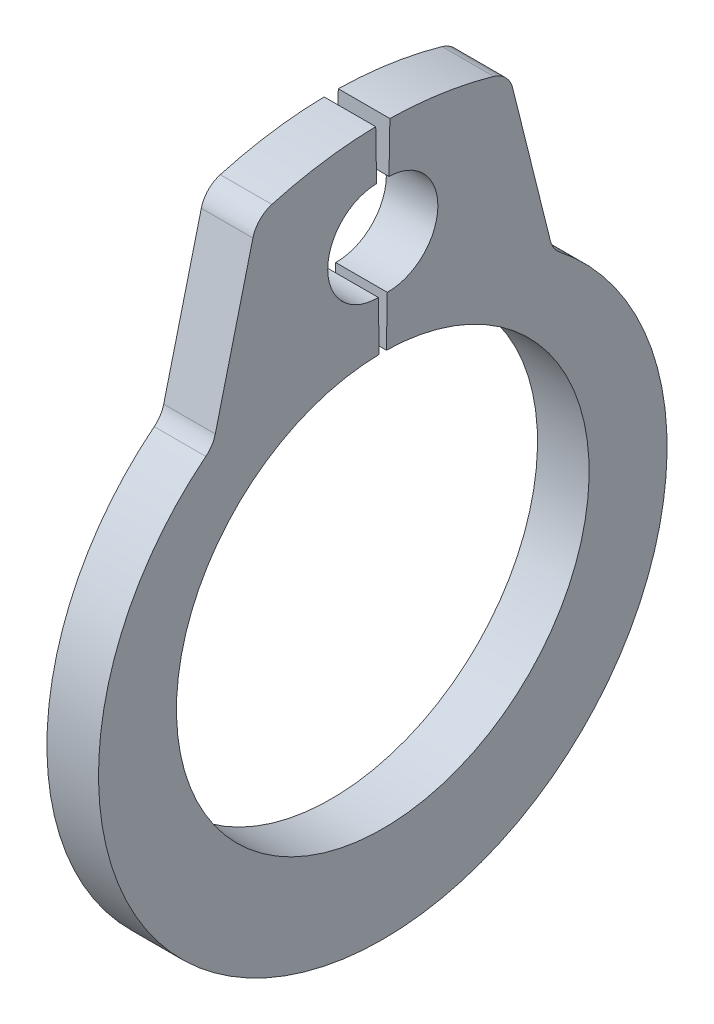
from build123d import *

# Parameters (mm, degrees)
EXTRUDE1_DEPTH = 0.35
FILLET1_R      = 0.37


with BuildPart() as part:
    # Sketch1 → Extrude1 (new body, symmetric)
    with BuildSketch(Plane(origin=(0, 0, 0), x_dir=(0, 0, -1), z_dir=(1, 0, 0))):
        with BuildLine():
            Line((0.048866738, 2.799573546), (0.060647112, 3.474470741))
            ThreePointArc((0.060647112, 3.474470741), (0.747324681, 4.137587561), (0.084207861, 4.824265129))
            Line((0.084207861, 4.824265129), (0.095988235, 5.499162323))
            ThreePointArc((0.095988235, 5.499162323), (0.91428004, 5.423476008), (1.712160583, 5.226710834))
            Line((1.712160583, 5.226710834), (2.304187375, 2.852221062))
            ThreePointArc((2.304187375, 2.852221062), (0, -4.1), (-2.304187375, 2.852221062))
            Line((-2.304187375, 2.852221062), (-1.712160583, 5.226710834))
            ThreePointArc((-1.712160583, 5.226710834), (-0.91428004, 5.423476008), (-0.095988235, 5.499162323))
            Line((-0.095988235, 5.499162323), (-0.084207861, 4.824265129))
            ThreePointArc((-0.084207861, 4.824265129), (-0.747324681, 4.137587561), (-0.060647112, 3.474470741))
            Line((-0.060647112, 3.474470741), (-0.048866738, 2.799573546))
            ThreePointArc((-0.048866738, 2.799573546), (0, -2.8), (0.048866738, 2.799573546))
        make_face()
    extrude(amount=EXTRUDE1_DEPTH, both=True)

    # Fillet1
    fillet1_edges = [part.edges().sort_by_distance(p)[0] for p in [
        (0, 5.226710834, -1.712160583),
        (0, 2.852221062, -2.304187375),
        (0, 2.852221062, 2.304187375),
        (0, 5.226710834, 1.712160583),
    ]]
    fillet(fillet1_edges, radius=FILLET1_R)


solid = part.part
